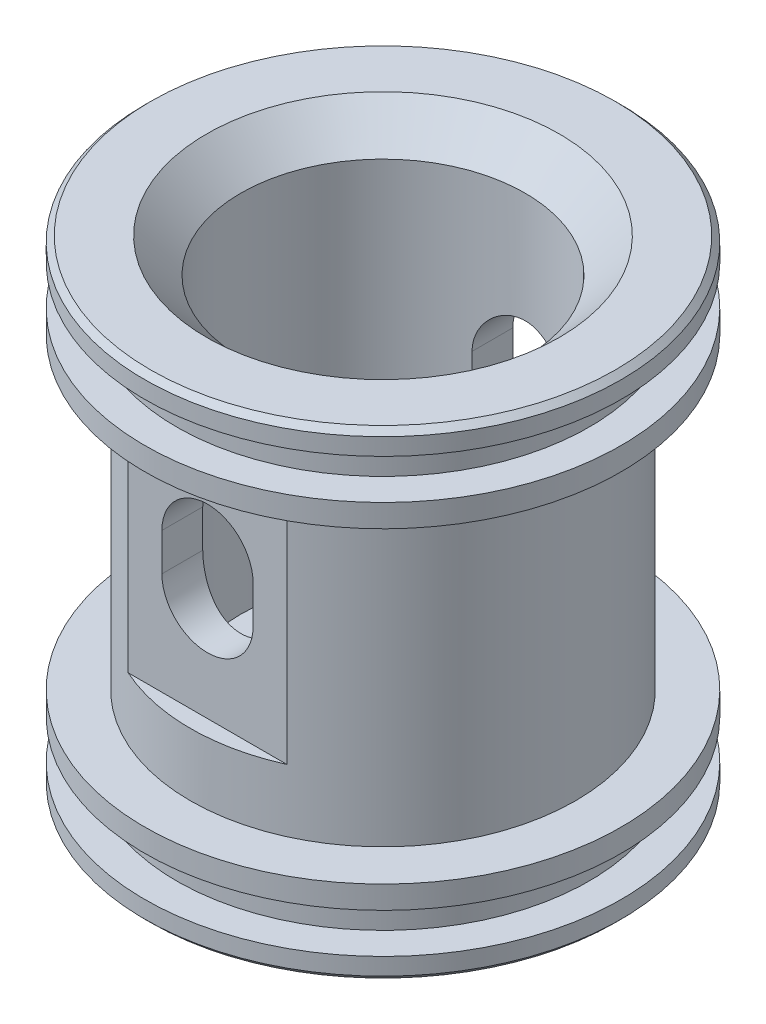
from build123d import *

# Parameters (mm, degrees)
CHAMFER1_SIZE           = 3
CHAMFER2_SIZE           = 0.5
SKETCH2_R               = 4
CUT_EXTRUDE1_DEPTH      = 43
SKETCH3_W               = 1.5
SKETCH3_H               = 21.5
CUT_EXTRUDE2_DEPTH      = 21.9
CUT_EXTRUDE2_DEPTH_BACK = 21.9
CUT_EXTRUDE3_DEPTH      = 6.5
CUT_EXTRUDE3_DEPTH_BACK = 37.3


with BuildPart() as part:
    # Sketch1 → Revolve1 (revolve)
    with BuildSketch(Plane.XY, mode=Mode.PRIVATE) as revolve1_sk:
        Polygon((0, 0), (12.475, 0), (12.475, 35), (20.9, 35), (20.9, 33), (18.1, 33), (18.1, 29.5), (20.9, 29.5), (20.9, 27.5), (16.9, 27.5), (16.9, 0.5), (20.9, 0.5), (20.9, -1.5), (18.1, -1.5), (18.1, -5), (20.9, -5), (20.9, -7), (0, -7), align=None)
    revolve(revolve1_sk.sketch.rotate(Axis((0, 0, 0), (0, -1, 0)), 180), axis=Axis((0, 0, 0), (0, -1, 0)))  # turned: the seam where the file's is

    # Chamfer1
    chamfer1_edges = [part.edges().sort_by_distance(p)[0] for p in [
        (12.475, 35, 0),
    ]]
    chamfer(chamfer1_edges, length=CHAMFER1_SIZE)

    # Chamfer2
    chamfer2_edges = [part.edges().sort_by_distance(p)[0] for p in [
        (20.9, 35, 0),
        (20.9, -7, 0),
    ]]
    chamfer(chamfer2_edges, length=CHAMFER2_SIZE)

    # Sketch2 → Cut-Extrude1 (cut, through all)
    with BuildSketch(Plane.XZ.offset(7)):
        Circle(SKETCH2_R)
    extrude(amount=-CUT_EXTRUDE1_DEPTH, mode=Mode.SUBTRACT)

    # Sketch3 → Cut-Extrude2 (cut, two sides)
    with BuildSketch(Plane(origin=(0, 0, 0), x_dir=(0, 0, -1), z_dir=(1, 0, 0))) as cut_extrude2_sk:
        with Locations((16.15, 16.75)):
            Rectangle(SKETCH3_W, SKETCH3_H)
        with Locations((-16.15, 16.75)):
            Rectangle(SKETCH3_W, SKETCH3_H)
    extrude(amount=CUT_EXTRUDE2_DEPTH, mode=Mode.SUBTRACT)
    extrude(cut_extrude2_sk.sketch, amount=-CUT_EXTRUDE2_DEPTH_BACK, mode=Mode.SUBTRACT)

    # Sketch4 → Cut-Extrude3 (cut, two sides)
    with BuildSketch(Plane.XY.offset(15.4)) as cut_extrude3_sk:
        with BuildLine():
            Line((4, 18.3), (4, 15))
            ThreePointArc((4, 15), (0, 11), (-4, 15))
            Line((-4, 15), (-4, 18.3))
            ThreePointArc((-4, 18.3), (0, 22.3), (4, 18.3))
        make_face()
    extrude(amount=CUT_EXTRUDE3_DEPTH, mode=Mode.SUBTRACT)
    extrude(cut_extrude3_sk.sketch, amount=-CUT_EXTRUDE3_DEPTH_BACK, mode=Mode.SUBTRACT)


solid = part.part
